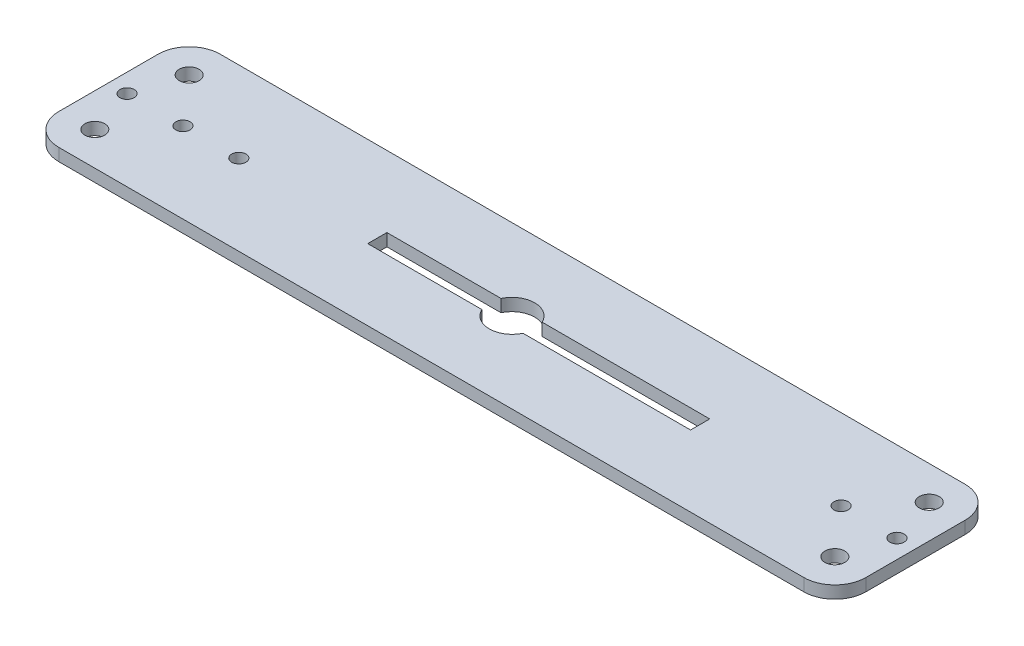
from build123d import *

# Parameters (mm, degrees)
ESBO_O1_R                = 1.6
ESBO_O1_R_2              = 1.15
RESSALTO_EXTRUS_O1_DEPTH = 2


with BuildPart() as part:
    # Esboço1 → Ressalto-extrusão1 (new body)
    with BuildSketch(Plane(origin=(0, 0, 0), x_dir=(1, 0, 0), z_dir=(0, 1, 0))):
        with BuildLine():
            Line((-60, -13), (60, -13))
            ThreePointArc((60, -13), (63.535533906, -11.535533906), (65, -8))
            Line((65, -8), (65, 8))
            ThreePointArc((65, 8), (63.535533906, 11.535533906), (60, 13))
            Line((60, 13), (-60, 13))
            ThreePointArc((-60, 13), (-63.535533906, 11.535533906), (-65, 8))
            Line((-65, 8), (-65, -8))
            ThreePointArc((-65, -8), (-63.535533906, -11.535533906), (-60, -13))
        make_face()
        with Locations((59.6, 7.6)):
            Circle(ESBO_O1_R, mode=Mode.SUBTRACT)
        with Locations((59.6, -7.6)):
            Circle(ESBO_O1_R, mode=Mode.SUBTRACT)
        with Locations((62, 0)):
            Circle(ESBO_O1_R_2, mode=Mode.SUBTRACT)
        with Locations((53, 0)):
            Circle(ESBO_O1_R_2, mode=Mode.SUBTRACT)
        with Locations((-59.6, 7.6)):
            Circle(ESBO_O1_R, mode=Mode.SUBTRACT)
        with Locations((-59.6, -7.6)):
            Circle(ESBO_O1_R, mode=Mode.SUBTRACT)
        with Locations((-53, 0)):
            Circle(ESBO_O1_R_2, mode=Mode.SUBTRACT)
        with Locations((-62, 0)):
            Circle(ESBO_O1_R_2, mode=Mode.SUBTRACT)
        with Locations((-44, 0)):
            Circle(ESBO_O1_R_2, mode=Mode.SUBTRACT)
        with BuildLine():
            Line((3.307143995, -1.544441193), (30.307143995, -1.544441193))
            Line((30.307143995, -1.544441193), (30.307143995, 1.544441193))
            Line((30.307143995, 1.544441193), (3.307143995, 1.544441193))
            ThreePointArc((3.307143995, 1.544441193), (0, 3.65), (-3.307143995, 1.544441193))
            Line((-3.307143995, 1.544441193), (-21.692856005, 1.544441193))
            Line((-21.692856005, 1.544441193), (-21.692856005, -1.544441193))
            Line((-21.692856005, -1.544441193), (-3.307143995, -1.544441193))
            ThreePointArc((-3.307143995, -1.544441193), (0, -3.65), (3.307143995, -1.544441193))
        make_face(mode=Mode.SUBTRACT)
    extrude(amount=RESSALTO_EXTRUS_O1_DEPTH)


solid = part.part
